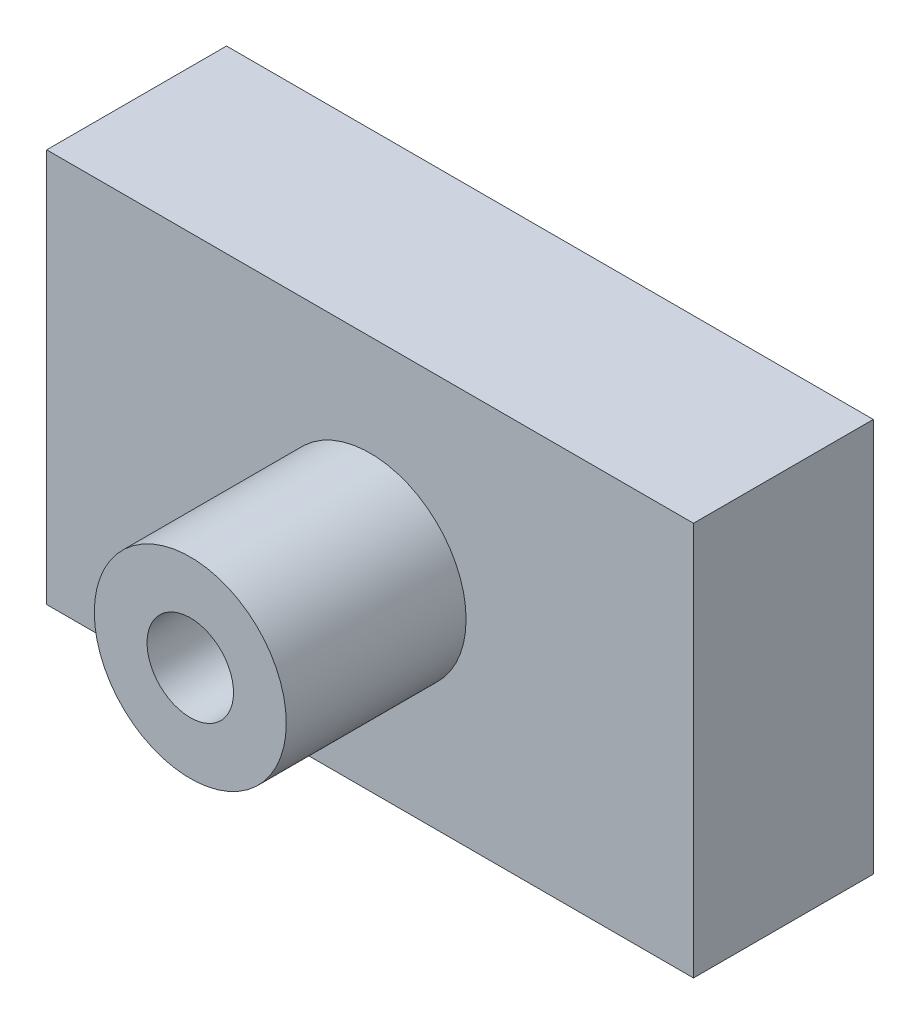
from build123d import *

# Parameters (mm, degrees)
SKETCH1_W           = 57.552398856
SKETCH1_H           = 35.043016192
BOSS_EXTRUDE1_DEPTH = 16
SKETCH2_R           = 8.540880827
BOSS_EXTRUDE2_DEPTH = 16
SKETCH3_R           = 3.847038177
CUT_EXTRUDE1_DEPTH  = 39


with BuildPart() as part:
    # Sketch1 → Boss-Extrude1 (new body)
    with BuildSketch(Plane.XY):
        Rectangle(SKETCH1_W, SKETCH1_H)
    extrude(amount=BOSS_EXTRUDE1_DEPTH)

    # Sketch2 → Boss-Extrude2 (add)
    with BuildSketch(Plane.XY.offset(16)):
        Circle(SKETCH2_R)
    extrude(amount=BOSS_EXTRUDE2_DEPTH)

    # Sketch3 → Cut-Extrude1 (cut)
    with BuildSketch(Plane.XY.offset(32)):
        Circle(SKETCH3_R)
    extrude(amount=-CUT_EXTRUDE1_DEPTH, mode=Mode.SUBTRACT)


solid = part.part
